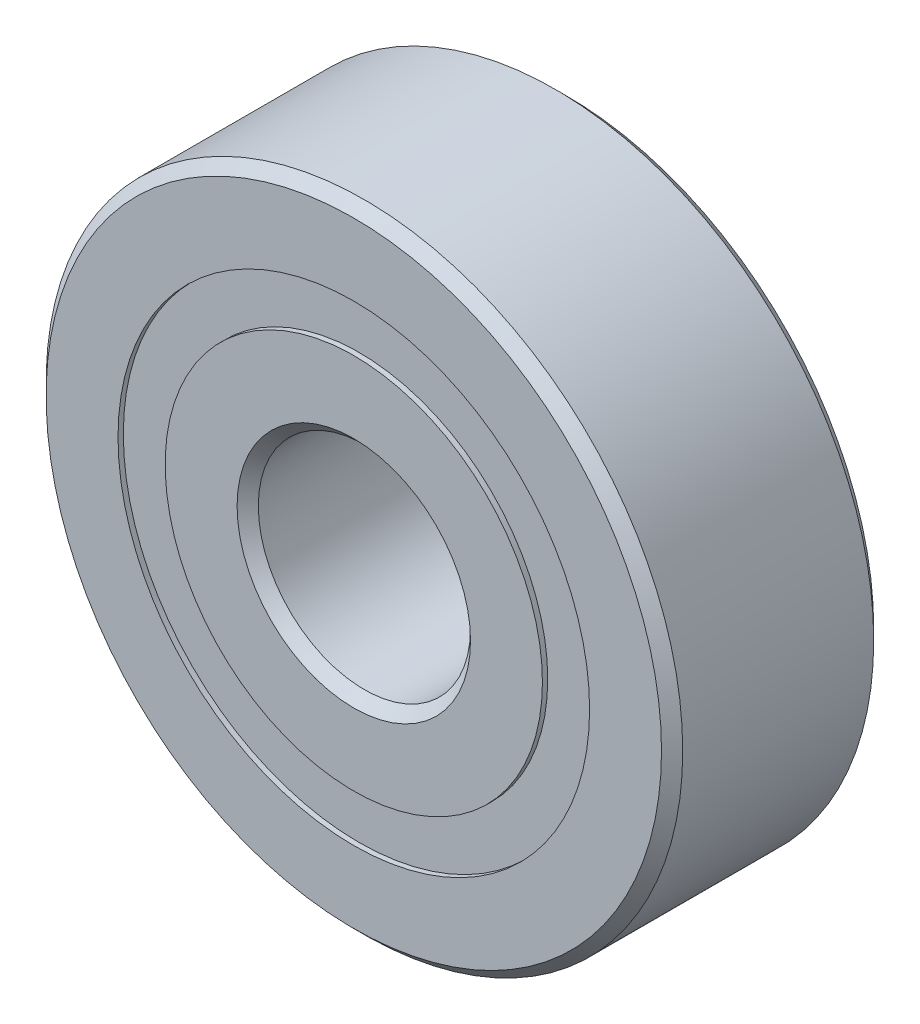
from build123d import *

# Parameters (mm, degrees)
CIRPATTERN1_COUNT = 12
SKETCH5_W         = 0.90619201
SKETCH5_H         = 0.888888888


with BuildPart() as part:
    # Sketch1 → Revolve1 (revolve)
    with BuildSketch(Plane(origin=(0, 0, 0), x_dir=(0, 0, -1), z_dir=(1, 0, 0))):
        with BuildLine():
            Line((1.8, 6), (-1.8, 6))
            Line((-1.8, 6), (-2, 5.8))
            Line((-2, 5.8), (-2, 4.444444444))
            Line((-2, 4.444444444), (-0.888888889, 4.444444444))
            ThreePointArc((-0.888888889, 4.444444444), (0, 4.99380799), (0.888888889, 4.444444444))
            Line((0.888888889, 4.444444444), (2, 4.444444444))
            Line((2, 4.444444444), (2, 5.8))
            Line((2, 5.8), (1.8, 6))
        make_face()
    revolve(axis=Axis((0, 0, 2), (0, 0, -1)))


with BuildPart() as body_2:
    # Sketch2 → Revolve2 (revolve)
    with BuildSketch(Plane(origin=(0, 0, 0), x_dir=(0, 0, -1), z_dir=(1, 0, 0))):
        with BuildLine():
            Line((-2, 3.555555556), (-0.888888889, 3.555555556))
            ThreePointArc((-0.888888889, 3.555555556), (0, 3.00619201), (0.888888889, 3.555555556))
            Line((0.888888889, 3.555555556), (2, 3.555555556))
            Line((2, 3.555555556), (2, 2.2))
            Line((2, 2.2), (1.8, 2))
            Line((1.8, 2), (-1.8, 2))
            Line((-1.8, 2), (-2, 2.2))
            Line((-2, 2.2), (-2, 3.555555556))
        make_face()
    revolve(axis=Axis((0, 0, 2), (0, 0, -1)))


with BuildPart() as body_3:
    # Sketch3 → Revolve3 (revolve)
    with BuildSketch(Plane(origin=(0, 0, 0), x_dir=(0, 0, -1), z_dir=(1, 0, 0))):
        with BuildLine():
            Line((-0.99380799, 4), (0.99380799, 4))
            ThreePointArc((0.99380799, 4), (0, 4.99380799), (-0.99380799, 4))
        make_face()
    revolve(axis=Axis((0, 4, 0.99380799), (0, 0, -1)))


with BuildPart() as cirpattern1_1:
    # CirPattern1: pattern copy
    add(body_3.part.rotate(Axis((0, 0, -2), (0, 0, 1)), 1 * 360 / CIRPATTERN1_COUNT))


with BuildPart() as cirpattern1_2:
    # CirPattern1: pattern copy
    add(body_3.part.rotate(Axis((0, 0, -2), (0, 0, 1)), 2 * 360 / CIRPATTERN1_COUNT))


with BuildPart() as cirpattern1_3:
    # CirPattern1: pattern copy
    add(body_3.part.rotate(Axis((0, 0, -2), (0, 0, 1)), 3 * 360 / CIRPATTERN1_COUNT))


with BuildPart() as cirpattern1_4:
    # CirPattern1: pattern copy
    add(body_3.part.rotate(Axis((0, 0, -2), (0, 0, 1)), 4 * 360 / CIRPATTERN1_COUNT))


with BuildPart() as cirpattern1_5:
    # CirPattern1: pattern copy
    add(body_3.part.rotate(Axis((0, 0, -2), (0, 0, 1)), 5 * 360 / CIRPATTERN1_COUNT))


with BuildPart() as cirpattern1_6:
    # CirPattern1: pattern copy
    add(body_3.part.rotate(Axis((0, 0, -2), (0, 0, 1)), 6 * 360 / CIRPATTERN1_COUNT))


with BuildPart() as cirpattern1_7:
    # CirPattern1: pattern copy
    add(body_3.part.rotate(Axis((0, 0, -2), (0, 0, 1)), 7 * 360 / CIRPATTERN1_COUNT))


with BuildPart() as cirpattern1_8:
    # CirPattern1: pattern copy
    add(body_3.part.rotate(Axis((0, 0, -2), (0, 0, 1)), 8 * 360 / CIRPATTERN1_COUNT))


with BuildPart() as cirpattern1_9:
    # CirPattern1: pattern copy
    add(body_3.part.rotate(Axis((0, 0, -2), (0, 0, 1)), 9 * 360 / CIRPATTERN1_COUNT))


with BuildPart() as cirpattern1_10:
    # CirPattern1: pattern copy
    add(body_3.part.rotate(Axis((0, 0, -2), (0, 0, 1)), 10 * 360 / CIRPATTERN1_COUNT))


with BuildPart() as cirpattern1_11:
    # CirPattern1: pattern copy
    add(body_3.part.rotate(Axis((0, 0, -2), (0, 0, 1)), 11 * 360 / CIRPATTERN1_COUNT))


with BuildPart() as body_15:
    # Sketch5 → Revolve5 (revolve)
    with BuildSketch(Plane(origin=(0, 0, 0), x_dir=(0, 0, -1), z_dir=(1, 0, 0))):
        with Locations((-1.446903995, 4)):
            Rectangle(SKETCH5_W, SKETCH5_H)
        with Locations((1.446903995, 4)):
            Rectangle(SKETCH5_W, SKETCH5_H)
    revolve(axis=Axis((0, 0, 2), (0, 0, -1)))


solid = Compound([part.part, body_2.part, body_3.part, cirpattern1_1.part, cirpattern1_2.part, cirpattern1_3.part, cirpattern1_4.part, cirpattern1_5.part, cirpattern1_6.part, cirpattern1_7.part, cirpattern1_8.part, cirpattern1_9.part, cirpattern1_10.part, cirpattern1_11.part, body_15.part])
